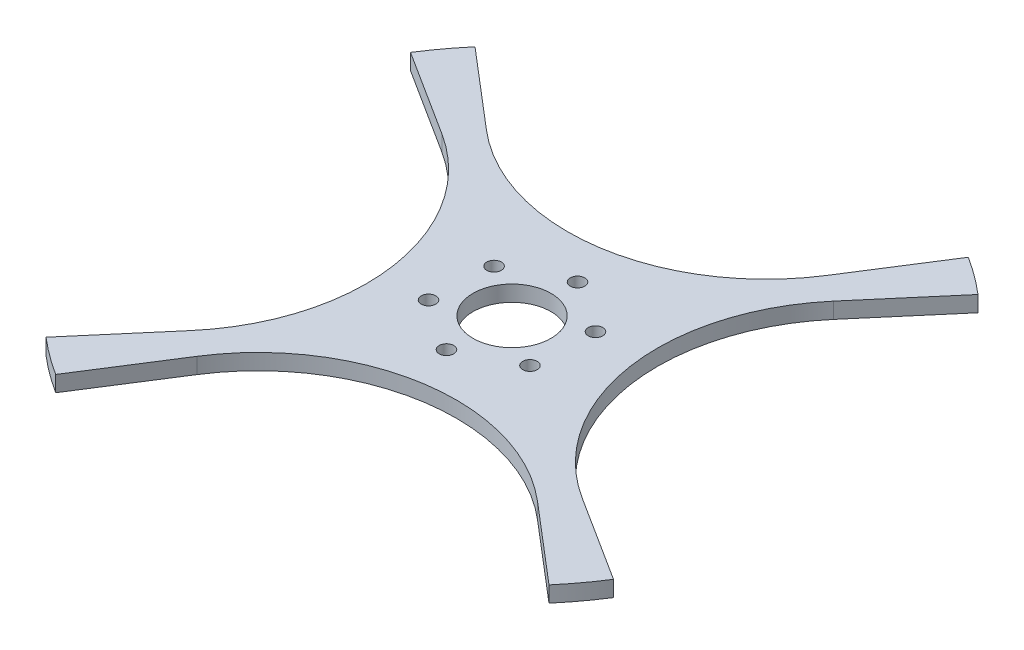
from build123d import *

# Parameters (mm, degrees)
SKETCH1_R           = 125
SKETCH1_R_2         = 14.75
BOSS_EXTRUDE1_DEPTH = 6
CUT_EXTRUDE1_DEPTH  = 6
CIRPATTERN1_COUNT   = 4
SKETCH3_R           = 2.75
CUT_EXTRUDE2_DEPTH  = 10


with BuildPart() as part:
    # Sketch1 → Boss-Extrude1 (new body)
    with BuildSketch(Plane(origin=(0, 0, 0), x_dir=(1, 0, 0), z_dir=(0, 1, 0))):
        Circle(SKETCH1_R)
        Circle(SKETCH1_R_2, mode=Mode.SUBTRACT)
    extrude(amount=BOSS_EXTRUDE1_DEPTH)

    # Sketch2 → Cut-Extrude1 (cut)
    with BuildSketch(Plane(origin=(0, 6, 0), x_dir=(1, 0, 0), z_dir=(0, 1, 0))):
        with BuildLine():
            Line((-46.306580885, -72.797871526), (-67.089494394, -105.470373764))
            Line((-67.089494394, -105.470373764), (-67.089494394, -164.92916021))
            Line((-67.089494394, -164.92916021), (95.10689036, -142.696592277))
            Line((95.10689036, -142.696592277), (95.10689036, -81.115223023))
            Line((95.10689036, -81.115223023), (65.644777188, -55.987433946))
            ThreePointArc((65.644777188, -55.987433946), (5.838619266, -38.883066128), (-46.306580885, -72.797871526))
        make_face()
    cut_extrude1 = extrude(amount=-CUT_EXTRUDE1_DEPTH, mode=Mode.SUBTRACT)

    # CirPattern1: Cut-Extrude1 ×4 about axis
    cirpattern1_axis = Axis((0, 0, 0), (0, 1, 0))
    for i in range(1, CIRPATTERN1_COUNT):
        add(cut_extrude1.rotate(cirpattern1_axis, i * 360 / CIRPATTERN1_COUNT), mode=Mode.SUBTRACT)

    # Sketch3 → Cut-Extrude2 (cut)
    with BuildSketch(Plane(origin=(0, 6, 0), x_dir=(1, 0, 0), z_dir=(0, 1, 0))):
        with Locations((-1.313428811, -23.463267137)):
            Circle(SKETCH3_R)
        with Locations((19.663070991, -12.869096285)):
            Circle(SKETCH3_R)
        with Locations((20.976499803, 10.594170852)):
            Circle(SKETCH3_R)
        with Locations((1.313428812, 23.463267137)):
            Circle(SKETCH3_R)
        with Locations((-19.663070991, 12.869096286)):
            Circle(SKETCH3_R)
        with Locations((-20.976499802, -10.594170852)):
            Circle(SKETCH3_R)
    extrude(amount=-CUT_EXTRUDE2_DEPTH, mode=Mode.SUBTRACT)


solid = part.part
